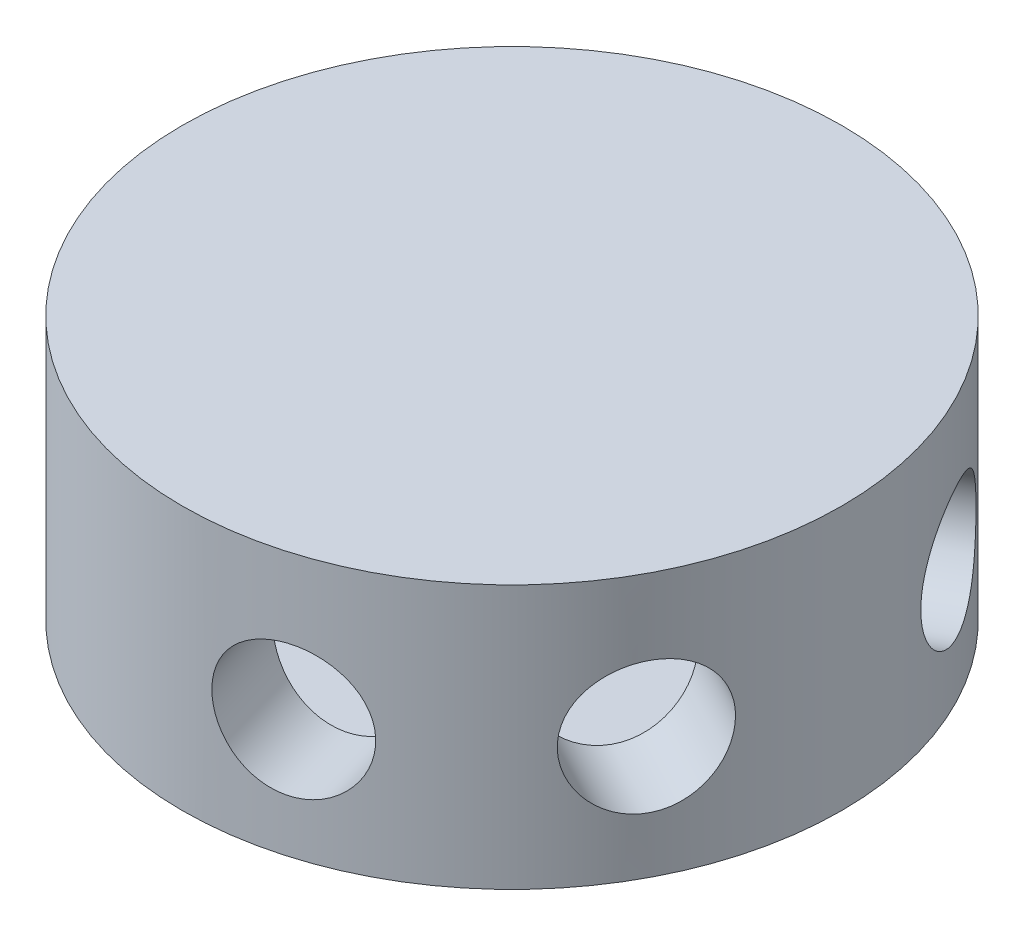
from build123d import *

# Parameters (mm, degrees)
SKETCH6_R                          = 15
BOSS_EXTRUDE3_DEPTH                = 12
CUT_EXTRUDE3_START                 = -2
SKETCH8_R                          = 11
CUT_EXTRUDE3_DEPTH                 = 8
F_6_0_6_DIAMETER_HOLE3_D           = 6
F_6_0_6_DIAMETER_HOLE3_ON_FACE_2_D = 6
F_6_0_6_DIAMETER_HOLE3_ON_FACE_3_D = 6


with BuildPart() as part:
    # Sketch6 → Boss-Extrude3 (new body)
    with BuildSketch(Plane(origin=(0, 0, 0), x_dir=(1, 0, 0), z_dir=(0, 1, 0))):
        Circle(SKETCH6_R)
    extrude(amount=BOSS_EXTRUDE3_DEPTH)

    # Sketch8 → Cut-Extrude3 (cut)
    with BuildSketch(Plane(origin=(0, 12, 0), x_dir=(1, 0, 0), z_dir=(0, 1, 0)).offset(CUT_EXTRUDE3_START)):
        Circle(SKETCH8_R)
    extrude(amount=-CUT_EXTRUDE3_DEPTH, mode=Mode.SUBTRACT)

    # Ø6.0 (6) Diameter Hole3 (through all)
    with Locations(Plane(origin=(13.257400922, 5.554097503, 7.017216029), x_dir=(-0.467814402, 0, 0.883826728), z_dir=(0.883826728, 0, 0.467814402))):
        with Locations((1e-09, 0)):
            Hole(F_6_0_6_DIAMETER_HOLE3_D / 2)

    # Ø6.0 (6) Diameter Hole3 on face 2 (through all)
    with Locations(Plane(origin=(13.269259555, 5.5012221, -6.994765961), x_dir=(0.466318067, 0, 0.884617127), z_dir=(0.884617127, 0, -0.466318067))):
        with Locations((0, 0)):
            Hole(F_6_0_6_DIAMETER_HOLE3_ON_FACE_2_D / 2)

    # Ø6.0 (6) Diameter Hole3 on face 3 (through all)
    with Locations(Plane(origin=(-4.253214755, 5.395471292, -14.384372223), x_dir=(-0.958958041, 0, 0.283548012), z_dir=(-0.283548012, 0, -0.958958041))):
        with Locations((0, 0)):
            Hole(F_6_0_6_DIAMETER_HOLE3_ON_FACE_3_D / 2)


solid = part.part
